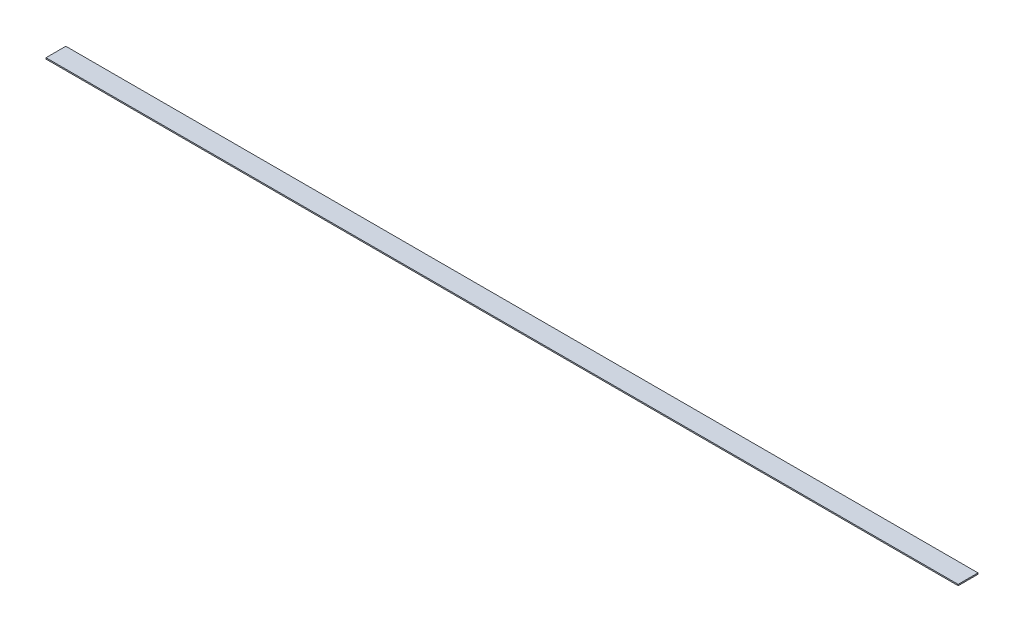
from build123d import *

# Parameters (mm, degrees)
SKETCH1_W           = 1168.4
SKETCH1_H           = 25.4
BOSS_EXTRUDE1_DEPTH = 1.5875


with BuildPart() as part:
    # Sketch1 → Boss-Extrude1 (new body)
    with BuildSketch(Plane(origin=(0, 0, 0), x_dir=(1, 0, 0), z_dir=(0, 1, 0))):
        with Locations((584.2, 12.7)):
            Rectangle(SKETCH1_W, SKETCH1_H)
    extrude(amount=BOSS_EXTRUDE1_DEPTH)


solid = part.part
